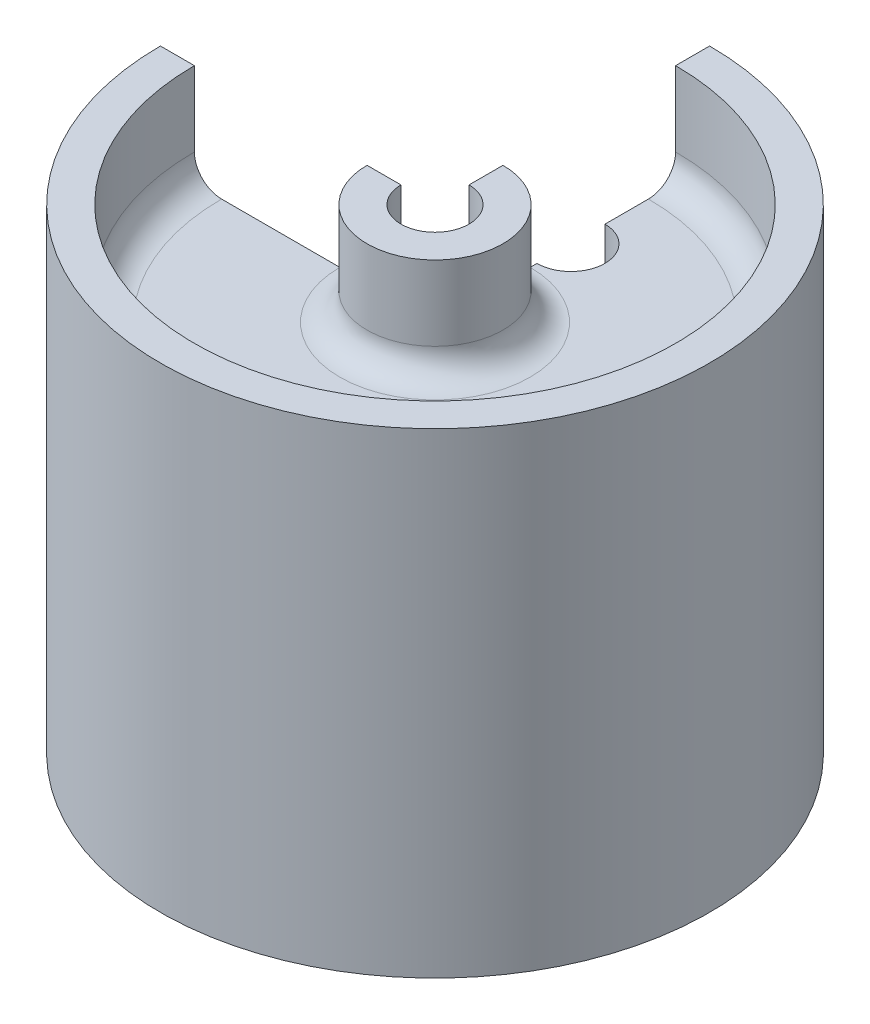
from build123d import *

# Parameters (mm, degrees)
REVOLVE2_ANGLE     = 270
SKETCH5_R          = 3.175
CUT_EXTRUDE1_DEPTH = 46.023434974
FILLET1_R          = 2.54
FILLET2_R          = 2.54


with BuildPart() as part:
    # Sketch1 → Revolve2 (revolve)
    with BuildSketch(Plane(origin=(0, 0, 0), x_dir=(0, 0, -1), z_dir=(1, 0, 0))):
        Polygon((22.479, 35.498434974), (22.479, 45.023434974), (25.654, 45.023434974), (25.654, 0.573434974), (22.479, 0.573434974), (22.479, 32.323434974), (6.35, 32.323434974), (6.35, 0.573434974), (3.175, 0.573434974), (3.175, 45.023434974), (6.35, 45.023434974), (6.35, 35.498434974), align=None)
    revolve(axis=Axis((0, 45.023434974, 0), (0, -1, 0)), revolution_arc=REVOLVE2_ANGLE)

    # Sketch5 → Cut-Extrude1 (cut, through all)
    with BuildSketch(Plane(origin=(0, 0, 0), x_dir=(1, 0, 0), z_dir=(0, 1, 0))):
        with Locations((0, 12.7)):
            Circle(SKETCH5_R)
    extrude(amount=CUT_EXTRUDE1_DEPTH, mode=Mode.SUBTRACT)

    # Fillet1
    fillet1_edges = [part.edges().sort_by_distance(p)[0] for p in [
        (15.895053334, 32.323434974, 15.895053334),
        (4.490128061, 32.323434974, 4.490128061),
    ]]
    fillet(fillet1_edges, radius=FILLET1_R)

    # Fillet2
    fillet2_edges = [part.edges().sort_by_distance(p)[0] for p in [
        (4.490128061, 35.498434974, 4.490128061),
        (15.895053334, 35.498434974, 15.895053334),
    ]]
    fillet(fillet2_edges, radius=FILLET2_R)


solid = part.part
